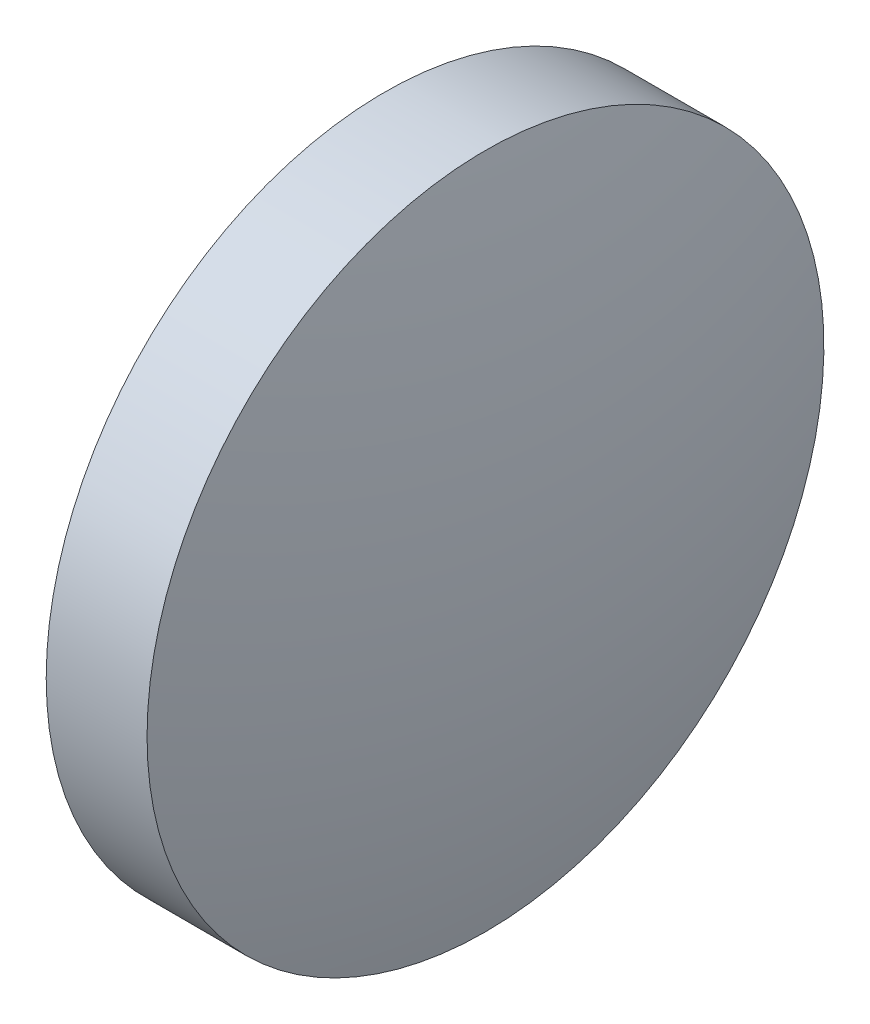
from build123d import *


with BuildPart() as part:
    # 草图1 → 旋转1 (revolve)
    with BuildSketch(Plane.XY, mode=Mode.PRIVATE) as revolve_1_sk:
        with BuildLine():
            Line((506.846941168, 24.748890306), (506.846941168, 29.748890306))
            Line((506.846941168, 29.748890306), (508.336941168, 29.748890306))
            ThreePointArc((508.336941168, 29.748890306), (508.813413924, 27.269043308), (508.973089432, 24.748890306))
            Line((508.973089432, 24.748890306), (506.846941168, 24.748890306))
        make_face()
    revolve(revolve_1_sk.sketch.rotate(Axis((505.905390696, 24.748890306, 0), (1, 0, 0)), 180), axis=Axis((505.905390696, 24.748890306, 0), (1, 0, 0)))  # turned: the seam where the file's is


solid = part.part
